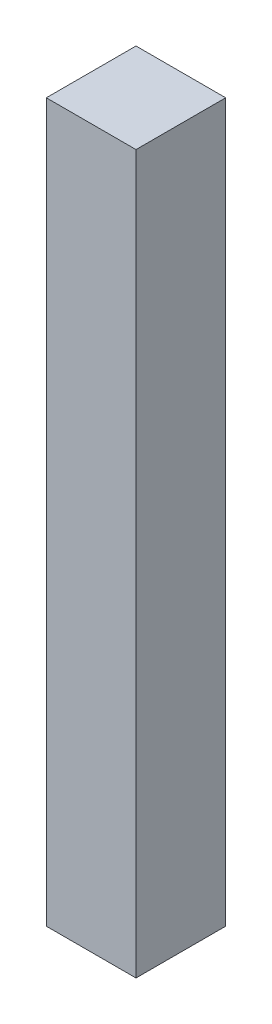
from build123d import *

# Parameters (mm, degrees)
SKETCH1_W           = 50
SKETCH1_H           = 50
BOSS_EXTRUDE1_DEPTH = 400


with BuildPart() as part:
    # Sketch1 → Boss-Extrude1 (new body)
    with BuildSketch(Plane(origin=(0, 0, 0), x_dir=(1, 0, 0), z_dir=(0, 1, 0))):
        with Locations((25, 25)):
            Rectangle(SKETCH1_W, SKETCH1_H)
    extrude(amount=BOSS_EXTRUDE1_DEPTH)


solid = part.part
